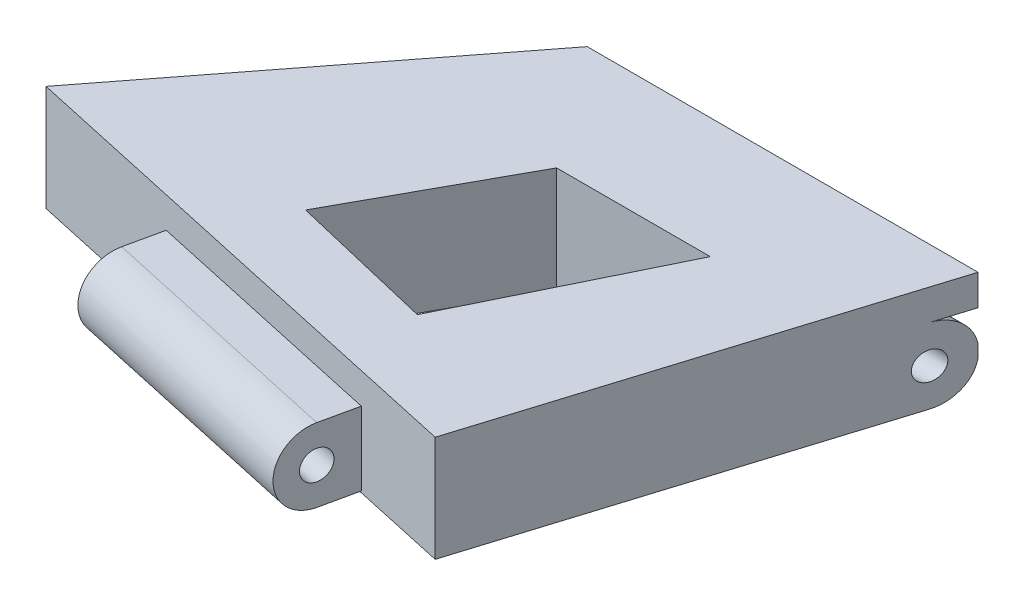
from build123d import *

# Parameters (mm, degrees)
BOSS_EXTRUDE1_DEPTH     = 15.24
CUT_EXTRUDE2_DEPTH      = 2.54
CUT_EXTRUDE3_DEPTH      = 26.416
CUT_EXTRUDE4_DEPTH      = 2.54
CUT_EXTRUDE5_DEPTH      = 37.592
CUT_EXTRUDE5_DEPTH_BACK = 16.256
SKETCH6_W               = 28.095448716
SKETCH6_H               = 6.506871402
CUT_EXTRUDE6_DEPTH      = 33.782
CUT_EXTRUDE6_DEPTH_BACK = 30.988
CUT_EXTRUDE7_DEPTH      = 30.988
BOSS_EXTRUDE2_DEPTH     = 2.54


with BuildPart() as part:
    # Sketch1 → Boss-Extrude1 (new body)
    with BuildSketch(Plane(origin=(0, 0, 0), x_dir=(1, 0, 0), z_dir=(0, 1, 0))):
        Polygon((0, 0), (19.056811247, 0), (19.056811247, 6.097892911), (26.173997358, 6.097892911), (15.563225472, -28.095448716), (7.752418672, -26.383450539), (6.430712527, -32.413592092), (-14.191226065, -27.893608153), (-12.86951992, -21.8634666), (-25.576280295, -19.078357307), (-6.082744599, 6.097892911), (0, 6.097892911), align=None)
    extrude(amount=BOSS_EXTRUDE1_DEPTH)

    # Sketch2 → Cut-Extrude2 (cut)
    with BuildSketch(Plane(origin=(0, 15.24, 0), x_dir=(1, 0, 0), z_dir=(0, 1, 0))):
        Polygon((-12.86951992, -21.8634666), (7.752418672, -26.383450539), (6.430712527, -32.413592092), (-14.191226065, -27.893608153), align=None)
    extrude(amount=-CUT_EXTRUDE2_DEPTH, mode=Mode.SUBTRACT)

    # Sketch3 → Cut-Extrude3 (cut)
    with BuildSketch(Plane(origin=(12.914786435, 0, 2.830705125), x_dir=(0.214100757, 0, -0.976811582), z_dir=(0.976811582, 0, 0.214100757))):
        with BuildLine():
            Line((-29.362167954, 11.792818882), (-30.285151737, 12.7))
            Line((-30.285151737, 12.7), (-30.285151737, 6.632404251))
            Line((-30.285151737, 6.632404251), (-27.19850654, 6.632404251))
            ThreePointArc((-27.19850654, 6.632404251), (-29.99633203, 8.493128354), (-29.362167954, 11.792818882))
        make_face()
        with BuildLine():
            Line((-27.19850654, 12.7), (-30.285151737, 12.7))
            Line((-30.285151737, 12.7), (-29.362167954, 11.792818882))
            ThreePointArc((-29.362167954, 11.792818882), (-28.371580312, 12.464027615), (-27.19850654, 12.7))
        make_face()
        with BuildLine():
            ThreePointArc((-25.999973236, 9.666202125), (-26.744632367, 10.775472298), (-28.053283414, 10.506344124))
            Line((-28.053283414, 10.506344124), (-26.343729666, 8.826060127))
            ThreePointArc((-26.343729666, 8.826060127), (-26.089236367, 9.212327952), (-25.999973236, 9.666202125))
        make_face()
        with BuildLine():
            Line((-26.343729666, 8.826060127), (-28.053283414, 10.506344124))
            ThreePointArc((-28.053283414, 10.506344124), (-28.038648539, 8.811425251), (-26.343729666, 8.826060127))
        make_face()
        Polygon((-27.19850654, 6.632404251), (-30.285151737, 6.632404251), (-30.285151737, 0), (-24.111861344, 0), (-24.111861344, 6.632404251), align=None)
    extrude(amount=-CUT_EXTRUDE3_DEPTH, mode=Mode.SUBTRACT)

    # Sketch4 → Cut-Extrude4 (cut)
    with BuildSketch(Plane(origin=(0, 15.24, 0), x_dir=(1, 0, 0), z_dir=(0, 1, 0))):
        Polygon((0, 0), (0, 6.097892911), (-6.082744599, 6.097892911), (-10.804237756, 0), align=None)
        Polygon((19.056811247, 0), (24.281718113, 0), (26.173997358, 6.097892911), (19.056811247, 6.097892911), align=None)
    extrude(amount=-CUT_EXTRUDE4_DEPTH, mode=Mode.SUBTRACT)

    # Sketch5 → Cut-Extrude5 (cut, two sides)
    with BuildSketch(Plane.ZY.offset(-19.056811247)) as cut_extrude5_sk:
        with BuildLine():
            ThreePointArc((-1.900262012, 9.603435701), (-2.605255865, 10.662970793), (-3.854871247, 10.421947266))
            Line((-3.854871247, 10.421947266), (-2.243021664, 8.784924136))
            ThreePointArc((-2.243021664, 8.784924136), (-1.989411364, 9.15974511), (-1.900262012, 9.603435701))
        make_face()
        with BuildLine():
            Line((-2.243021664, 8.784924136), (-3.854871247, 10.421947266))
            ThreePointArc((-3.854871247, 10.421947266), (-3.867458021, 8.79751091), (-2.243021664, 8.784924136))
        make_face()
        with BuildLine():
            ThreePointArc((-3.048946456, 6.506871402), (-5.038116892, 7.230270846), (-6.097892911, 9.062477322))
            Line((-6.097892911, 9.062477322), (-6.097892911, 6.506871402))
            Line((-6.097892911, 6.506871402), (-3.048946456, 6.506871402))
        make_face()
        Polygon((-3.048946456, 6.506871402), (-6.097892911, 6.506871402), (-6.097892911, 0), (0, 0), (0, 6.506871402), align=None)
        with BuildLine():
            Line((-5.221516955, 11.809936977), (-6.097892911, 12.7))
            Line((-6.097892911, 12.7), (-6.097892911, 10.14439408))
            ThreePointArc((-6.097892911, 10.14439408), (-5.789305577, 11.045358842), (-5.221516955, 11.809936977))
        make_face()
        with BuildLine():
            Line((-3.048946456, 12.7), (-6.097892911, 12.7))
            Line((-6.097892911, 12.7), (-5.221516955, 11.809936977))
            ThreePointArc((-5.221516955, 11.809936977), (-4.22285816, 12.468857444), (-3.048946456, 12.7))
        make_face()
    extrude(amount=CUT_EXTRUDE5_DEPTH, mode=Mode.SUBTRACT)
    extrude(cut_extrude5_sk.sketch, amount=-CUT_EXTRUDE5_DEPTH_BACK, mode=Mode.SUBTRACT)

    # Sketch6 → Cut-Extrude6 (cut, two sides)
    with BuildSketch(Plane(origin=(0, 0, 0), x_dir=(0, 0, -1), z_dir=(1, 0, 0))) as cut_extrude6_sk:
        with Locations((-14.047724358, 3.253435701)):
            Rectangle(SKETCH6_W, SKETCH6_H)
    extrude(amount=CUT_EXTRUDE6_DEPTH, mode=Mode.SUBTRACT)
    extrude(cut_extrude6_sk.sketch, amount=-CUT_EXTRUDE6_DEPTH_BACK, mode=Mode.SUBTRACT)

    # Sketch7 → Cut-Extrude7 (cut)
    with BuildSketch(Plane(origin=(0, 15.24, 0), x_dir=(1, 0, 0), z_dir=(0, 1, 0))):
        Polygon((14.008950707, -3.834200977), (7.607295542, -3.834200977), (0.172703368, -18.672351511), (6.066325192, -20.069477121), align=None)
        Polygon((0.172703368, -18.672351511), (7.607295542, -3.834200977), (1.320524054, -3.834200977), (-6.028876319, -17.202222267), align=None)
    extrude(amount=-CUT_EXTRUDE7_DEPTH, mode=Mode.SUBTRACT)

    # Sketch8 → Boss-Extrude2 (add)
    with BuildSketch(Plane(origin=(0, 15.24, 0), x_dir=(1, 0, 0), z_dir=(0, 1, 0))):
        Polygon((-10.804237756, 0), (24.281718113, 0), (26.173997358, 6.097892911), (-6.082744599, 6.097892911), align=None)
    extrude(amount=-BOSS_EXTRUDE2_DEPTH)


solid = part.part
